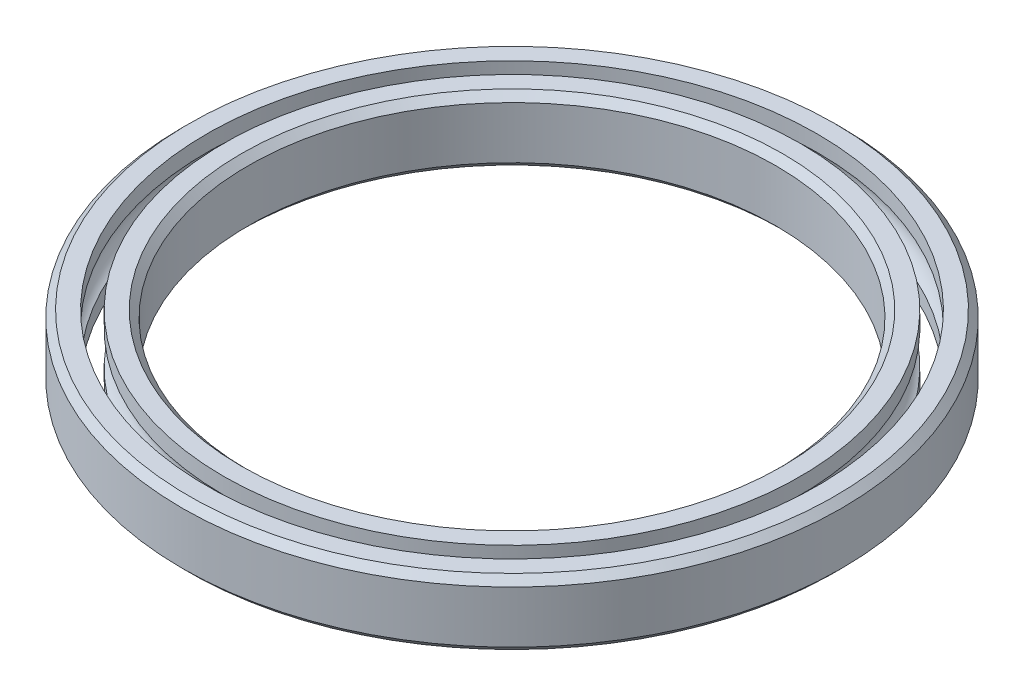
from build123d import *


with BuildPart() as part:
    # Sketch1 → Revolve1 (revolve)
    with BuildSketch(Plane.XY):
        with BuildLine():
            Line((-23.8125, -1.88125), (-23.8125, 1.88125))
            Line((-23.8125, 1.88125), (-23.3125, 2.38125))
            Line((-23.3125, 2.38125), (-22.0345, 2.38125))
            Line((-22.0345, 2.38125), (-22.0345, 1.217995801))
            ThreePointArc((-22.0345, 1.217995801), (-22.790449887, 0), (-22.0345, -1.217995801))
            Line((-22.0345, -1.217995801), (-22.0345, -2.38125))
            Line((-22.0345, -2.38125), (-23.3125, -2.38125))
            Line((-23.3125, -2.38125), (-23.8125, -1.88125))
        make_face()
        with BuildLine():
            Line((-19.05, -1.88125), (-19.55, -2.38125))
            Line((-19.55, -2.38125), (-20.828, -2.38125))
            Line((-20.828, -2.38125), (-20.828, -1.217995801))
            ThreePointArc((-20.828, -1.217995801), (-20.072050113, 0), (-20.828, 1.217995801))
            Line((-20.828, 1.217995801), (-20.828, 2.38125))
            Line((-20.828, 2.38125), (-19.55, 2.38125))
            Line((-19.55, 2.38125), (-19.05, 1.88125))
            Line((-19.05, 1.88125), (-19.05, -1.88125))
        make_face()
    revolve(axis=Axis((0, 0, 0), (0, 1, 0)))


solid = part.part
